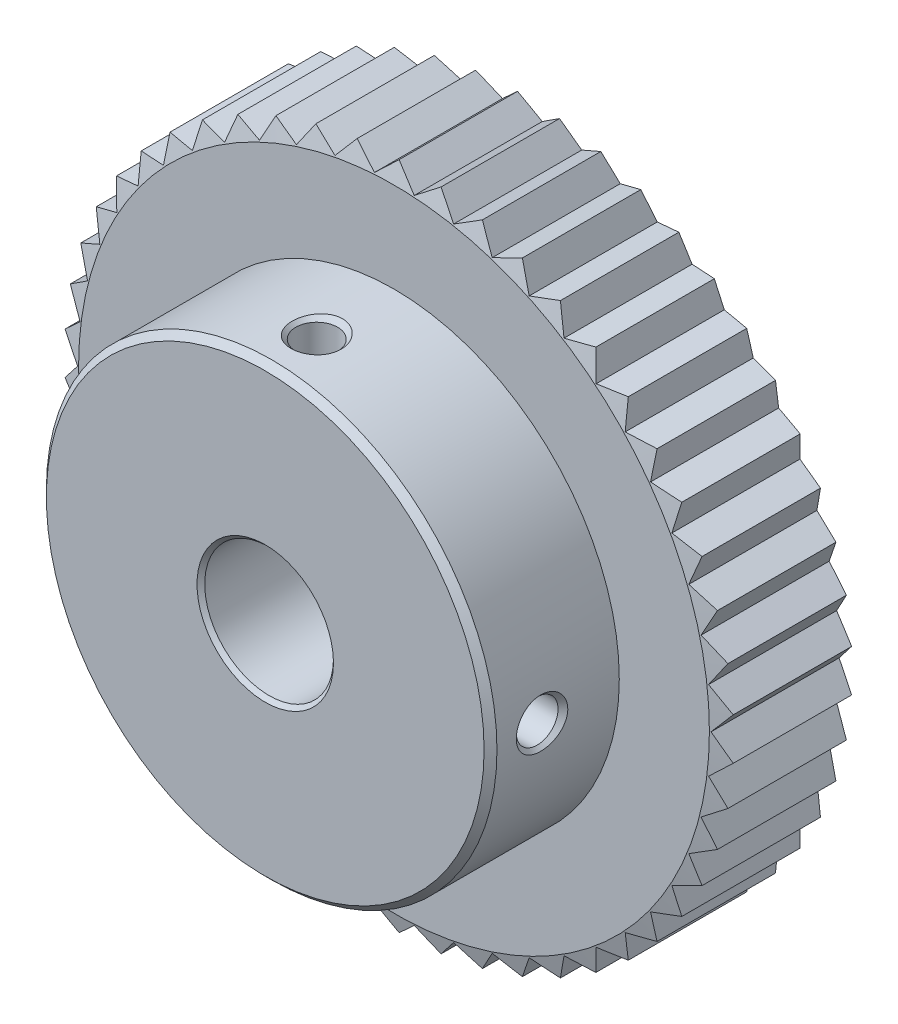
from build123d import *

# Parameters (mm, degrees)
SKETCH2_R          = 52
CUT_EXTRUDE1_DEPTH = 10


with BuildPart() as part:
    # Sketch1 → Revolve1 (revolve)
    with BuildSketch(Plane(origin=(0, 0, 0), x_dir=(0, 0, -1), z_dir=(1, 0, 0))):
        Polygon((-20, 5.3), (-19.7, 5), (-0.3, 5), (0, 5.3), (0, 24.5), (-0.669872981, 27), (-9.330127019, 27), (-10, 24.5), (-10, 17.5), (-19.5, 17.5), (-20, 17), align=None)
    revolve(axis=Axis((0, 0, 0), (0, 0, 1)))

    # Sketch2 → Cut-Extrude1 (cut)
    with BuildSketch(Plane.XY):
        Circle(SKETCH2_R)
        Polygon((-25.948694939, -1.632553508), (-24.406021652, -3.083197546), (-25.539468519, -4.871914179), (-23.827145764, -6.117771224), (-24.727469424, -8.034441854), (-22.872501553, -9.055863996), (-23.525503364, -11.070261581), (-21.557144329, -11.851140383), (-21.952526063, -13.931496669), (-19.901818062, -14.459517206), (-20.033344312, -16.573023733), (-17.932628235, -16.839858806), (-17.798224754, -18.953184313), (-15.680630148, -18.954625772), (-15.28241656, -21.034441854), (-13.181339156, -20.770466967), (-12.525595527, -22.783973681), (-10.474170573, -22.258745491), (-9.57123837, -24.174188633), (-7.601818062, -23.395990301), (-6.465937066, -25.183162189), (-4.609580339, -24.164266368), (-3.258664073, -25.794982234), (-1.54464678, -24.551457519), (0, -26), (1.54464678, -24.551457519), (3.258664073, -25.794982234), (4.609580339, -24.164266368), (6.465937066, -25.183162189), (7.601818062, -23.395990301), (9.57123837, -24.174188633), (10.474170573, -22.258745491), (12.525595527, -22.783973681), (13.181339156, -20.770466967), (15.28241656, -21.034441854), (15.680630148, -18.954625772), (17.798224754, -18.953184313), (17.932628235, -16.839858806), (20.033344312, -16.573023733), (19.901818062, -14.459517206), (21.952526063, -13.931496669), (21.557144329, -11.851140383), (23.525503364, -11.070261581), (22.872501553, -9.055863996), (24.727469424, -8.034441854), (23.827145764, -6.117771224), (25.539468519, -4.871914179), (24.406021652, -3.083197546), (25.948694939, -1.632553508), (24.6, 0), (25.948694939, 1.632553508), (24.406021652, 3.083197546), (25.539468519, 4.871914179), (23.827145764, 6.117771224), (24.727469424, 8.034441854), (22.872501553, 9.055863996), (23.525503364, 11.070261581), (21.557144329, 11.851140383), (21.952526063, 13.931496669), (19.901818062, 14.459517206), (20.033344312, 16.573023733), (17.932628235, 16.839858806), (17.798224754, 18.953184313), (15.680630148, 18.954625772), (15.28241656, 21.034441854), (13.181339156, 20.770466967), (12.525595527, 22.783973681), (10.474170573, 22.258745491), (9.57123837, 24.174188633), (7.601818062, 23.395990301), (6.465937066, 25.183162189), (4.609580339, 24.164266368), (3.258664073, 25.794982234), (1.54464678, 24.551457519), (0, 26), (-1.54464678, 24.551457519), (-3.258664073, 25.794982234), (-4.609580339, 24.164266368), (-6.465937066, 25.183162189), (-7.601818062, 23.395990301), (-9.57123837, 24.174188633), (-10.474170573, 22.258745491), (-12.525595527, 22.783973681), (-13.181339156, 20.770466967), (-15.28241656, 21.034441854), (-15.680630148, 18.954625772), (-17.798224754, 18.953184313), (-17.932628235, 16.839858806), (-20.033344312, 16.573023733), (-19.901818062, 14.459517206), (-21.952526063, 13.931496669), (-21.557144329, 11.851140383), (-23.525503364, 11.070261581), (-22.872501553, 9.055863996), (-24.727469424, 8.034441854), (-23.827145764, 6.117771224), (-25.539468519, 4.871914179), (-24.406021652, 3.083197546), (-25.948694939, 1.632553508), (-24.6, 0), align=None, mode=Mode.SUBTRACT)
    extrude(amount=CUT_EXTRUDE1_DEPTH, mode=Mode.SUBTRACT)

    # Sketch3 → Cut-Revolve1 (revolve, cut)
    with BuildSketch(Plane.XY.offset(16)):
        Polygon((0, 0), (-2, 0), (-2, 5), (-1.621, 5.379), (-1.621, 17.121), (-2, 17.5), (-2, 27.5), (0, 27.5), align=None)
    revolve(axis=Axis((0, 27.5, 16), (0, -1, 0)), mode=Mode.SUBTRACT)

    # Sketch4 → Cut-Revolve2 (revolve, cut)
    with BuildSketch(Plane.XY.offset(16)):
        Polygon((0, 0), (0, 2), (5, 2), (5.379, 1.621), (17.121, 1.621), (17.5, 2), (27.5, 2), (27.5, 0), align=None)
    revolve(axis=Axis((27.5, 0, 16), (-1, 0, 0)), mode=Mode.SUBTRACT)


solid = part.part
